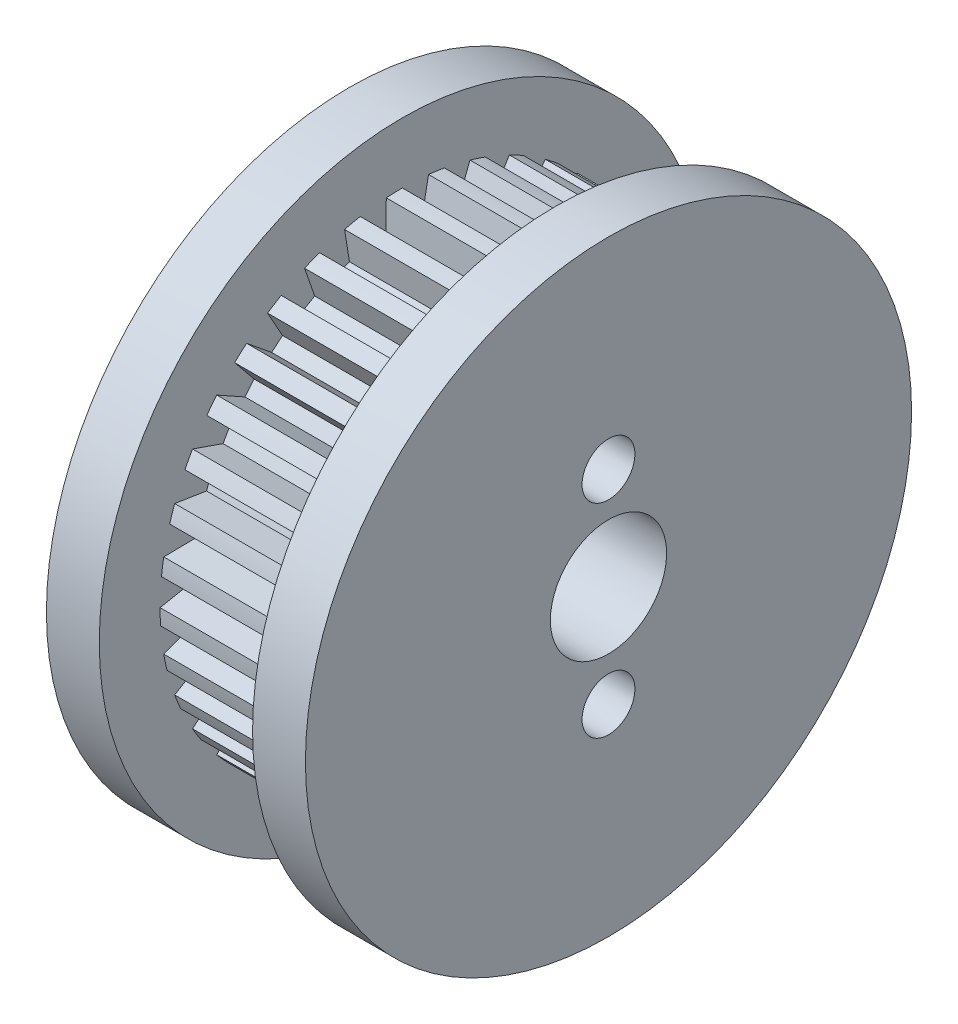
from build123d import *

# Parameters (mm, degrees)
CUT_EXTRUDE1_DEPTH = 7.366
CIRPATTERN1_COUNT  = 36
SKETCH5_R          = 1.27
CUT_EXTRUDE2_DEPTH = 22.86


with BuildPart() as part:
    # Sketch2 → Revolve1 (revolve)
    with BuildSketch(Plane.XY):
        Polygon((-6.223, 2.794), (6.223, 2.794), (6.223, 14.56436), (3.683, 14.56436), (3.683, 11.64336), (-3.683, 11.64336), (-3.683, 14.56436), (-6.223, 14.56436), align=None)
    revolve(axis=Axis((-20.14780731, 0, 0), (1, 0, 0)))

    # Sketch3 → Cut-Extrude1 (cut)
    with BuildSketch(Plane.ZY.offset(-3.683)):
        Polygon((-1.27, 11.64336), (-0.9779, 10.11936), (-0.2921, 10.11936), (0, 11.64336), align=None)
    cut_extrude1 = extrude(amount=CUT_EXTRUDE1_DEPTH, mode=Mode.SUBTRACT)

    # CirPattern1: Cut-Extrude1 ×36 about axis
    cirpattern1_axis = Axis((0, 0, 0), (1, 0, 0))
    for i in range(1, CIRPATTERN1_COUNT):
        add(cut_extrude1.rotate(cirpattern1_axis, i * 360 / CIRPATTERN1_COUNT), mode=Mode.SUBTRACT)

    # Sketch5 → Cut-Extrude2 (cut)
    with BuildSketch(Plane.ZY.offset(6.223)):
        with Locations((0, 4.8895)):
            Circle(SKETCH5_R)
        with Locations((0, -4.8895)):
            Circle(SKETCH5_R)
    extrude(amount=-CUT_EXTRUDE2_DEPTH, mode=Mode.SUBTRACT)


solid = part.part
